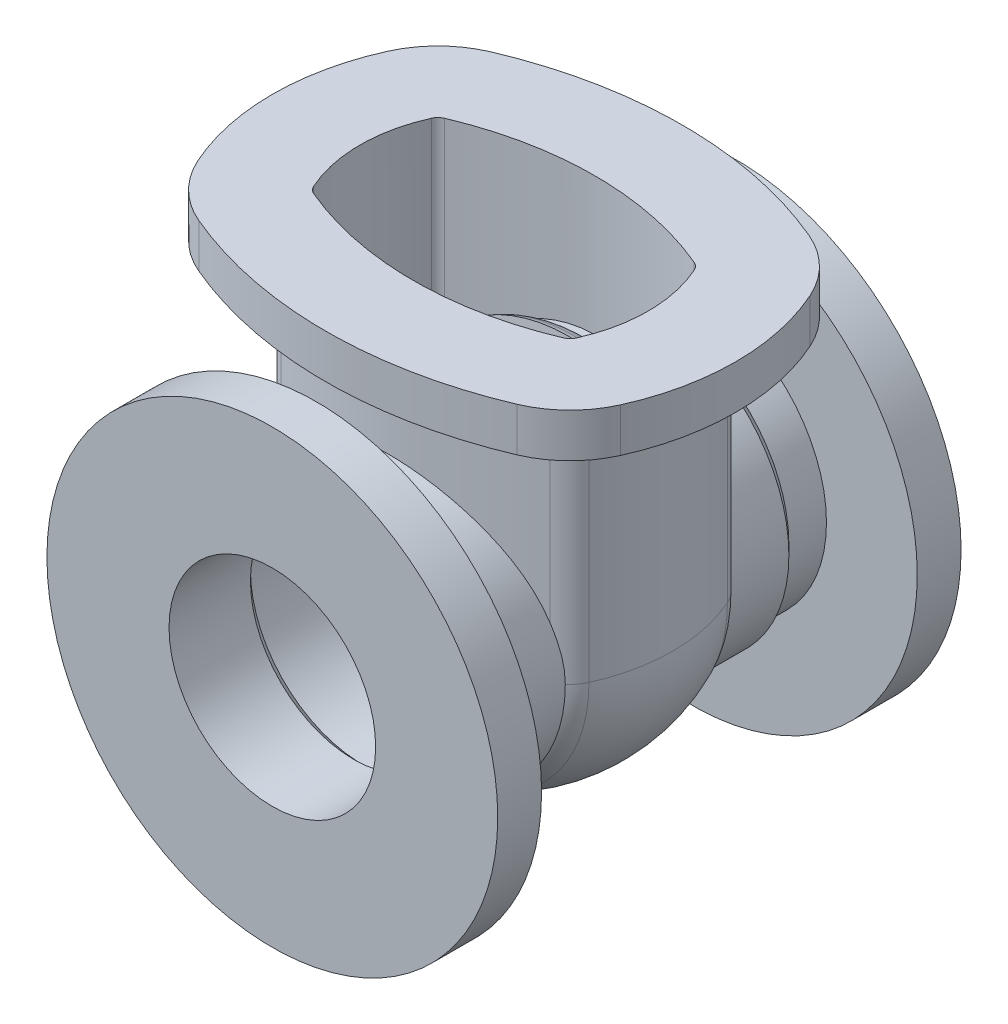
from build123d import *

# Parameters (mm, degrees)
CUT_EXTRUDE1_DEPTH             = 115.3
CUT_EXTRUDE1_DEPTH_BACK        = 115.3
BOSS_EXTRUDE1_DEPTH            = 142.875
BOSS_EXTRUDE2_DEPTH            = 22.225
CUT_EXTRUDE2_REACH             = 119.475
CUT_EXTRUDE2_DIRECTION_2_REACH = 119.475


with BuildPart() as part:
    # Sketch1 → Revolve1 (revolve)
    with BuildSketch(Plane(origin=(0, 0, 0), x_dir=(0, 0, -1), z_dir=(1, 0, 0))):
        with BuildLine():
            Line((-76.2, -52.3875), (-117.475, -52.3875))
            Line((-117.475, -52.3875), (-117.475, -114.3))
            Line((-117.475, -114.3), (-95.25, -114.3))
            Line((-95.25, -114.3), (-95.25, -68.2625))
            Line((-95.25, -68.2625), (-76.2, -68.2625))
            Line((-76.2, -68.2625), (-71.4375, -73.025))
            Line((-71.4375, -73.025), (-41.936651857, -73.025))
            ThreePointArc((-41.936651857, -73.025), (-43.560758987, -70.75739219), (-44.836334568, -68.276933343))
            ThreePointArc((-44.836334568, -68.276933343), (-47.073606935, -62.750045829), (-49.120888044, -57.15))
            Line((-49.120888044, -57.15), (-71.4375, -57.15))
            Line((-71.4375, -57.15), (-76.2, -52.3875))
        make_face()
        with BuildLine():
            ThreePointArc((0, -73.025), (15.290494263, -71.406242095), (29.903094423, -66.621734959))
            ThreePointArc((29.903094423, -66.621734959), (31.838045941, -65.273118673), (33.147328418, -63.311338191))
            ThreePointArc((33.147328418, -63.311338191), (34.41368905, -60.243324902), (35.616899689, -57.15))
            Line((35.616899689, -57.15), (49.120888044, -57.15))
            ThreePointArc((49.120888044, -57.15), (47.073606935, -62.750045829), (44.836334568, -68.276933343))
            ThreePointArc((44.836334568, -68.276933343), (40.908487139, -74.162274791), (35.103632583, -78.208123648))
            ThreePointArc((35.103632583, -78.208123648), (17.949710657, -83.824718982), (0, -85.725))
            ThreePointArc((0, -85.725), (-17.949710657, -83.824718982), (-35.103632583, -78.208123648))
            ThreePointArc((-35.103632583, -78.208123648), (-40.908487139, -74.162274791), (-44.836334568, -68.276933343))
            ThreePointArc((-44.836334568, -68.276933343), (-47.073606935, -62.750045829), (-49.120888044, -57.15))
            Line((-49.120888044, -57.15), (-35.616899689, -57.15))
            ThreePointArc((-35.616899689, -57.15), (-34.41368905, -60.243324902), (-33.147328418, -63.311338191))
            ThreePointArc((-33.147328418, -63.311338191), (-31.838045941, -65.273118673), (-29.903094423, -66.621734959))
            ThreePointArc((-29.903094423, -66.621734959), (-15.290494263, -71.406242095), (0, -73.025))
        make_face()
        with BuildLine():
            ThreePointArc((44.836334568, -68.276933343), (43.560758987, -70.75739219), (41.936651857, -73.025))
            Line((41.936651857, -73.025), (71.4375, -73.025))
            Line((71.4375, -73.025), (76.2, -68.2625))
            Line((76.2, -68.2625), (95.25, -68.2625))
            Line((95.25, -68.2625), (95.25, -114.3))
            Line((95.25, -114.3), (117.475, -114.3))
            Line((117.475, -114.3), (117.475, -52.3875))
            Line((117.475, -52.3875), (76.2, -52.3875))
            Line((76.2, -52.3875), (71.4375, -57.15))
            Line((71.4375, -57.15), (49.120888044, -57.15))
            ThreePointArc((49.120888044, -57.15), (47.073606935, -62.750045829), (44.836334568, -68.276933343))
        make_face()
    revolve(axis=Axis((0, 0, 117.475), (0, 0, -1)))

    # Sketch2 → Cut-Extrude1 (cut, two sides)
    with BuildSketch(Plane(origin=(0, 0, 0), x_dir=(0, 0, -1), z_dir=(1, 0, 0))) as cut_extrude1_sk:
        Polygon((-25.4, 0), (-35.399954241, 114.3), (35.399954241, 114.3), (25.4, 0), align=None)
    extrude(amount=CUT_EXTRUDE1_DEPTH, mode=Mode.SUBTRACT)
    extrude(cut_extrude1_sk.sketch, amount=-CUT_EXTRUDE1_DEPTH_BACK, mode=Mode.SUBTRACT)

    # Sketch3 → Boss-Extrude1 (add)
    with BuildSketch(Plane(origin=(0, 142.875, 0), x_dir=(1, 0, 0), z_dir=(0, 1, 0))):
        with BuildLine():
            ThreePointArc((78.208123648, -35.103632583), (85.725, 0), (78.208123648, 35.103632583))
            ThreePointArc((78.208123648, 35.103632583), (74.162274791, 40.908487139), (68.276933343, 44.836334568))
            ThreePointArc((68.276933343, 44.836334568), (0, 58.7375), (-68.276933343, 44.836334568))
            ThreePointArc((-68.276933343, 44.836334568), (-74.162274791, 40.908487139), (-78.208123648, 35.103632583))
            ThreePointArc((-78.208123648, 35.103632583), (-85.725, 0), (-78.208123648, -35.103632583))
            ThreePointArc((-78.208123648, -35.103632583), (-74.162274791, -40.908487139), (-68.276933343, -44.836334568))
            ThreePointArc((-68.276933343, -44.836334568), (0, -58.7375), (68.276933343, -44.836334568))
            ThreePointArc((68.276933343, -44.836334568), (74.162274791, -40.908487139), (78.208123648, -35.103632583))
        make_face()
        with BuildLine():
            ThreePointArc((66.621734959, -29.903094423), (65.273118673, -31.838045941), (63.311338191, -33.147328418))
            ThreePointArc((63.311338191, -33.147328418), (0, -46.0375), (-63.311338191, -33.147328418))
            ThreePointArc((-63.311338191, -33.147328418), (-65.273118673, -31.838045941), (-66.621734959, -29.903094423))
            ThreePointArc((-66.621734959, -29.903094423), (-73.025, 0), (-66.621734959, 29.903094423))
            ThreePointArc((-66.621734959, 29.903094423), (-65.273118673, 31.838045941), (-63.311338191, 33.147328418))
            ThreePointArc((-63.311338191, 33.147328418), (0, 46.0375), (63.311338191, 33.147328418))
            ThreePointArc((63.311338191, 33.147328418), (65.273118673, 31.838045941), (66.621734959, 29.903094423))
            ThreePointArc((66.621734959, 29.903094423), (73.025, 0), (66.621734959, -29.903094423))
        make_face(mode=Mode.SUBTRACT)
    extrude(amount=-BOSS_EXTRUDE1_DEPTH)

    # Sketch3_3 → Boss-Extrude2 (add)
    with BuildSketch(Plane(origin=(0, 142.875, 0), x_dir=(1, 0, 0), z_dir=(0, 1, 0))):
        with BuildLine():
            ThreePointArc((107.174095369, -48.104977984), (117.475, 0), (107.174095369, 48.104977984))
            ThreePointArc((107.174095369, 48.104977984), (96.385165084, 63.584590133), (80.690921224, 74.058849944))
            ThreePointArc((80.690921224, 74.058849944), (0, 90.4875), (-80.690921224, 74.058849944))
            ThreePointArc((-80.690921224, 74.058849944), (-96.385165084, 63.584590133), (-107.174095369, 48.104977984))
            ThreePointArc((-107.174095369, 48.104977984), (-117.475, 0), (-107.174095369, -48.104977984))
            ThreePointArc((-107.174095369, -48.104977984), (-96.385165084, -63.584590133), (-80.690921224, -74.058849944))
            ThreePointArc((-80.690921224, -74.058849944), (0, -90.4875), (80.690921224, -74.058849944))
            ThreePointArc((80.690921224, -74.058849944), (96.385165084, -63.584590133), (107.174095369, -48.104977984))
        make_face()
        with BuildLine():
            ThreePointArc((78.208123648, 35.103632583), (74.162274791, 40.908487139), (68.276933343, 44.836334568))
            ThreePointArc((68.276933343, 44.836334568), (0, 58.7375), (-68.276933343, 44.836334568))
            ThreePointArc((-68.276933343, 44.836334568), (-74.162274791, 40.908487139), (-78.208123648, 35.103632583))
            ThreePointArc((-78.208123648, 35.103632583), (-85.725, 0), (-78.208123648, -35.103632583))
            ThreePointArc((-78.208123648, -35.103632583), (-74.162274791, -40.908487139), (-68.276933343, -44.836334568))
            ThreePointArc((-68.276933343, -44.836334568), (0, -58.7375), (68.276933343, -44.836334568))
            ThreePointArc((68.276933343, -44.836334568), (74.162274791, -40.908487139), (78.208123648, -35.103632583))
            ThreePointArc((78.208123648, -35.103632583), (85.725, 0), (78.208123648, 35.103632583))
        make_face(mode=Mode.SUBTRACT)
    extrude(amount=-BOSS_EXTRUDE2_DEPTH)

    # Sketch5 → Cut-Extrude2 (cut, up to next)
    with BuildSketch(Plane.XY, mode=Mode.PRIVATE) as cut_extrude2_sk1:
        with BuildLine():
            Line((-57.15, 0), (57.15, 0))
            ThreePointArc((57.15, 0), (0, 57.15), (-57.15, 0))
        make_face()
    cut_extrude2_tool1 = extrude(cut_extrude2_sk1.sketch, amount=CUT_EXTRUDE2_REACH, mode=Mode.PRIVATE) & part.part
    add(cut_extrude2_tool1.solids().sort_by_distance((0, 24.255213, 0))[0], mode=Mode.SUBTRACT)

    # Sketch5 → Cut-Extrude2 direction 2 (cut, up to next)
    with BuildSketch(Plane.XY, mode=Mode.PRIVATE) as cut_extrude2_direction_2_sk1:
        with BuildLine():
            Line((-57.15, 0), (57.15, 0))
            ThreePointArc((57.15, 0), (0, 57.15), (-57.15, 0))
        make_face()
    cut_extrude2_direction_2_tool1 = extrude(cut_extrude2_direction_2_sk1.sketch, amount=-CUT_EXTRUDE2_DIRECTION_2_REACH, mode=Mode.PRIVATE) & part.part
    add(cut_extrude2_direction_2_tool1.solids().sort_by_distance((0, 24.255213, 0))[0], mode=Mode.SUBTRACT)


solid = part.part
